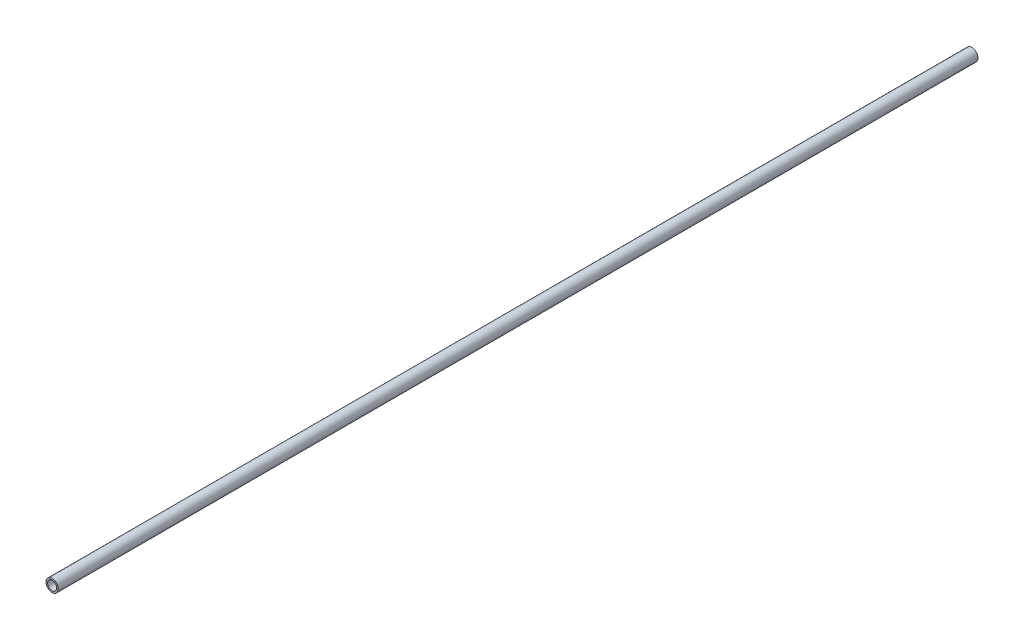
from build123d import *

# Parameters (mm, degrees)
PIPESKETCH_R    = 36.576
PIPESKETCH_R_2  = 27.051
EXTRUSION_DEPTH = 5486.4


with BuildPart() as part:
    # PipeSketch → Extrusion (new body)
    with BuildSketch(Plane.XY):
        Circle(PIPESKETCH_R)
        Circle(PIPESKETCH_R_2, mode=Mode.SUBTRACT)
    extrude(amount=EXTRUSION_DEPTH)


solid = part.part
